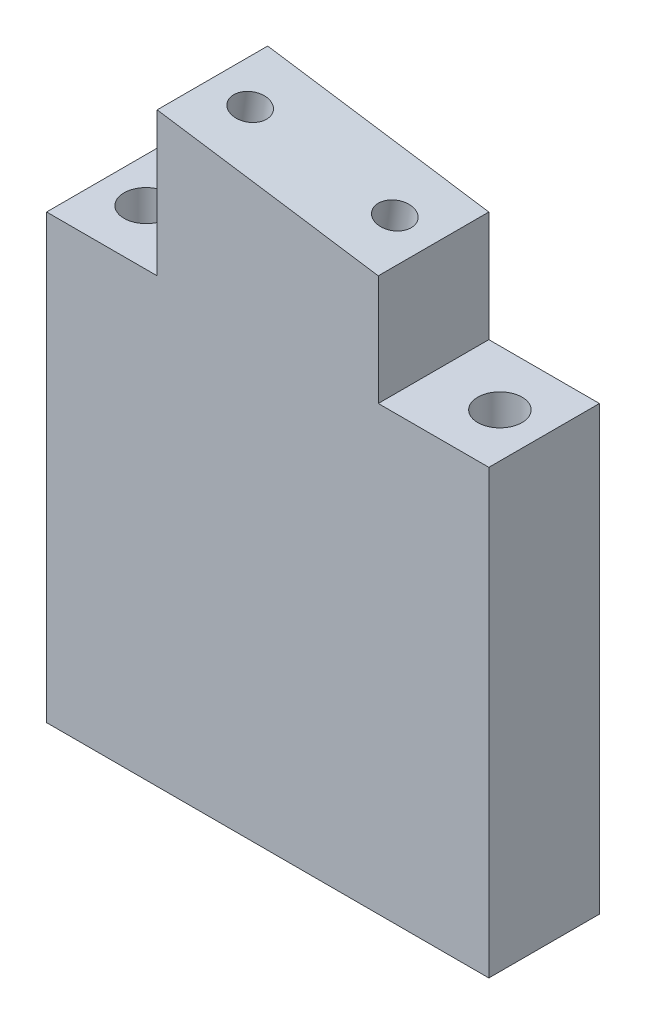
from build123d import *

# Parameters (mm, degrees)
BOSS_EXTRU_1_DEPTH      = 10
ESQUISSE4_R             = 1.5
ENL_V_MAT_EXTRU_3_DEPTH = 10
ESQUISSE2_R             = 2
ENL_V_MAT_EXTRU_4_DEPTH = 50


with BuildPart() as part:
    # Esquisse1 → Boss.-Extru.1 (new body)
    with BuildSketch(Plane.XY):
        Polygon((-13.347674419, 16.395348837), (-3.347674419, 16.395348837), (-3.347674419, 26.395348837), (-3.347674419, 29.395348837), (16.652325581, 26.395348837), (16.652325581, 16.395348837), (26.652325581, 16.395348837), (26.652325581, -23.604651163), (-13.347674419, -23.604651163), align=None)
    extrude(amount=BOSS_EXTRU_1_DEPTH)

    # Esquisse4 → Enlèv. mat.-Extru.3 (cut)
    with BuildSketch(Plane(origin=(4.238610906, 28.257406039, 0), x_dir=(0.988936353, -0.148340453, 0), z_dir=(0.148340453, 0.988936353, 0))):
        with Locations((-4.171156291, -5.047200532)):
            Circle(ESQUISSE4_R)
        with Locations((9.052592125, -5.047200532)):
            Circle(ESQUISSE4_R)
    extrude(amount=-ENL_V_MAT_EXTRU_3_DEPTH, mode=Mode.SUBTRACT)

    # Esquisse2 → Enlèv. mat.-Extru.4 (cut)
    with BuildSketch(Plane(origin=(0, 16.395348837, 0), x_dir=(1, 0, 0), z_dir=(0, 1, 0))):
        with Locations((22.652325581, -5)):
            Circle(ESQUISSE2_R)
        with Locations((-9.347674419, -5)):
            Circle(ESQUISSE2_R)
    extrude(amount=-ENL_V_MAT_EXTRU_4_DEPTH, mode=Mode.SUBTRACT)


solid = part.part
